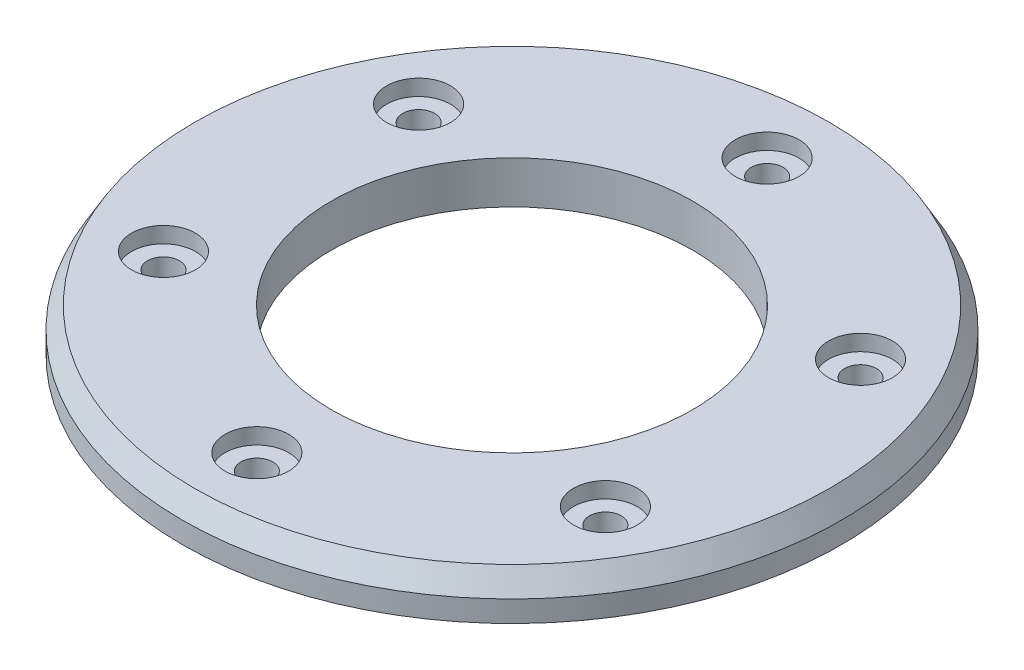
from build123d import *

# Parameters (mm, degrees)
SKETCH1_R           = 31
SKETCH1_R_2         = 17
SKETCH1_R_3         = 1.5
BOSS_EXTRUDE1_DEPTH = 4
SKETCH2_R           = 3
CUT_EXTRUDE1_DEPTH  = 1.5
CHAMFER1_SIZE       = 2
CHAMFER1_SIZE2      = 1.154700538


with BuildPart() as part:
    # Sketch1 → Boss-Extrude1 (new body)
    with BuildSketch(Plane(origin=(0, 0, 0), x_dir=(1, 0, 0), z_dir=(0, 1, 0))):
        Circle(SKETCH1_R)
        Circle(SKETCH1_R_2, mode=Mode.SUBTRACT)
        with Locations((0, 24)):
            Circle(SKETCH1_R_3, mode=Mode.SUBTRACT)
        with Locations((20.784609691, 12)):
            Circle(SKETCH1_R_3, mode=Mode.SUBTRACT)
        with Locations((20.784609691, -12)):
            Circle(SKETCH1_R_3, mode=Mode.SUBTRACT)
        with Locations((0, -24)):
            Circle(SKETCH1_R_3, mode=Mode.SUBTRACT)
        with Locations((-20.784609691, -12)):
            Circle(SKETCH1_R_3, mode=Mode.SUBTRACT)
        with Locations((-20.784609691, 12)):
            Circle(SKETCH1_R_3, mode=Mode.SUBTRACT)
    extrude(amount=BOSS_EXTRUDE1_DEPTH)

    # Sketch2 → Cut-Extrude1 (cut)
    with BuildSketch(Plane(origin=(0, 4, 0), x_dir=(1, 0, 0), z_dir=(0, 1, 0))):
        with Locations((0, 24)):
            Circle(SKETCH2_R)
        with Locations((20.784609691, 12)):
            Circle(SKETCH2_R)
        with Locations((20.784609691, -12)):
            Circle(SKETCH2_R)
        with Locations((0, -24)):
            Circle(SKETCH2_R)
        with Locations((-20.784609691, -12)):
            Circle(SKETCH2_R)
        with Locations((-20.784609691, 12)):
            Circle(SKETCH2_R)
    extrude(amount=-CUT_EXTRUDE1_DEPTH, mode=Mode.SUBTRACT)

    # Chamfer1
    chamfer1_edges = [part.edges().sort_by_distance(p)[0] for p in [
        (-31, 4, 0),
    ]]
    chamfer1_side = [part.faces().sort_by_distance(p)[0] for p in [
        (-31, 2, 0),
    ]]
    chamfer(chamfer1_edges, length=CHAMFER1_SIZE, length2=CHAMFER1_SIZE2, reference=chamfer1_side[0])


solid = part.part
